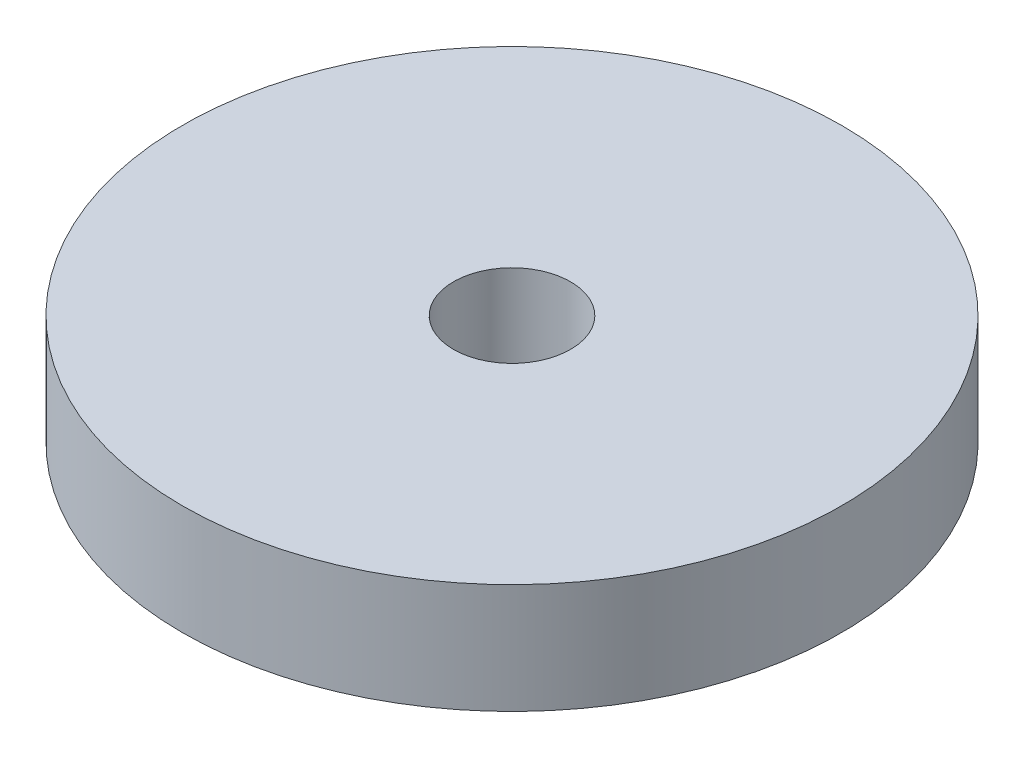
from build123d import *

# Parameters (mm, degrees)
SKETCH1_R           = 9
SKETCH1_R_2         = 1.6
BOSS_EXTRUDE1_DEPTH = 3


with BuildPart() as part:
    # Sketch1 → Boss-Extrude1 (new body)
    with BuildSketch(Plane(origin=(0, 0, 0), x_dir=(1, 0, 0), z_dir=(0, 1, 0))):
        Circle(SKETCH1_R)
        Circle(SKETCH1_R_2, mode=Mode.SUBTRACT)
    extrude(amount=BOSS_EXTRUDE1_DEPTH)


solid = part.part
